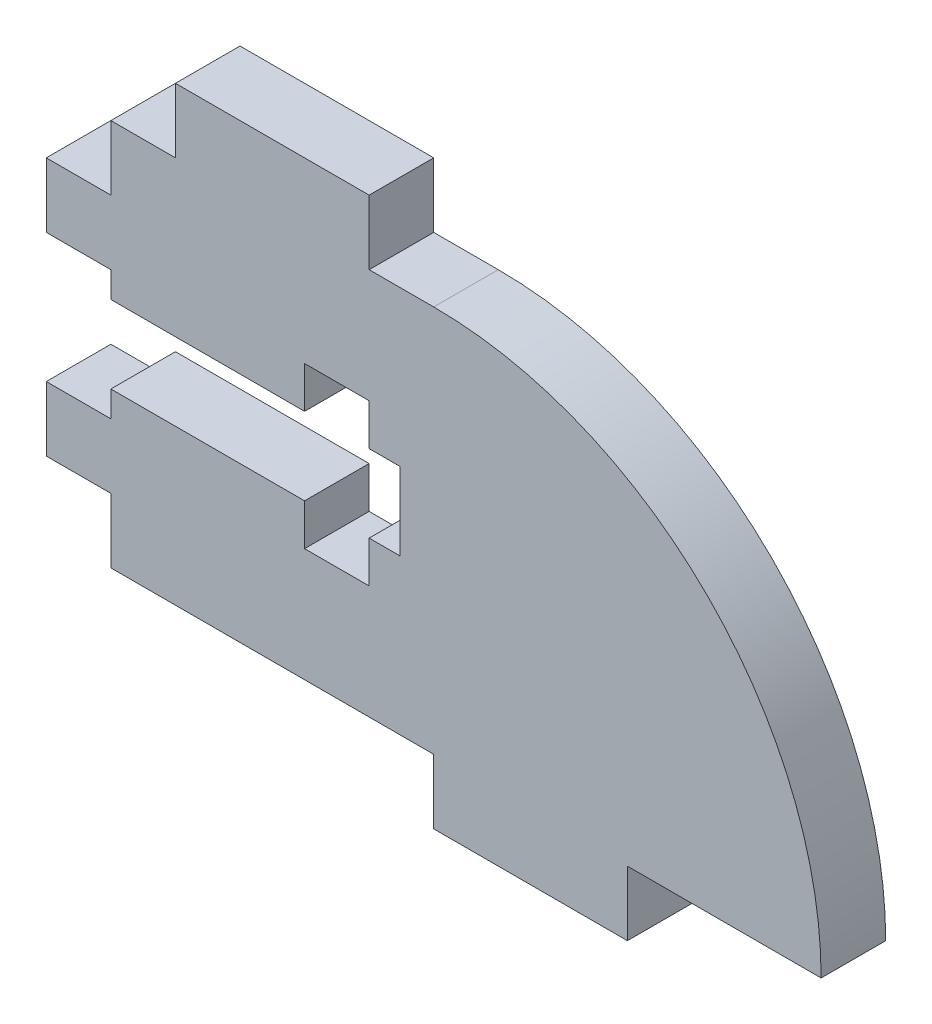
from build123d import *

# Parameters (mm, degrees)
BOSS_EXTRUDE1_DEPTH = 3.175


with BuildPart() as part:
    # Sketch1 → Boss-Extrude1 (new body)
    with BuildSketch(Plane.XY):
        with BuildLine():
            Line((0, 0), (0, 3.175))
            Line((0, 3.175), (-3.175, 3.175))
            Line((-3.175, 3.175), (-3.175, 6.35))
            Line((-3.175, 6.35), (0, 6.35))
            Line((0, 6.35), (0, 7.62))
            Line((0, 7.62), (9.525, 7.62))
            Line((9.525, 7.62), (9.525, 5.582477749))
            Line((9.525, 5.582477749), (12.7, 5.582477749))
            Line((12.7, 5.582477749), (12.7, 7.62))
            Line((12.7, 7.62), (14.224, 7.62))
            Line((14.224, 7.62), (14.224, 11.43))
            Line((14.224, 11.43), (12.7, 11.43))
            Line((12.7, 11.43), (12.7, 13.467522251))
            Line((12.7, 13.467522251), (9.525, 13.467522251))
            Line((9.525, 13.467522251), (9.525, 11.43))
            Line((9.525, 11.43), (0, 11.43))
            Line((0, 11.43), (0, 12.7))
            Line((0, 12.7), (-3.175, 12.7))
            Line((-3.175, 12.7), (-3.175, 15.875))
            Line((-3.175, 15.875), (0, 15.875))
            Line((0, 15.875), (0, 19.05))
            Line((0, 19.05), (3.175, 19.05))
            Line((3.175, 19.05), (3.175, 22.225))
            Line((3.175, 22.225), (12.7, 22.225))
            Line((12.7, 22.225), (12.7, 19.05))
            Line((12.7, 19.05), (15.875, 19.05))
            ThreePointArc((15.875, 19.05), (29.345384182, 13.470384182), (34.925, 0))
            Line((34.925, 0), (25.4, 0))
            Line((25.4, 0), (25.4, -3.175))
            Line((25.4, -3.175), (15.875, -3.175))
            Line((15.875, -3.175), (15.875, 0))
            Line((15.875, 0), (0, 0))
        make_face()
    extrude(amount=BOSS_EXTRUDE1_DEPTH)


solid = part.part
